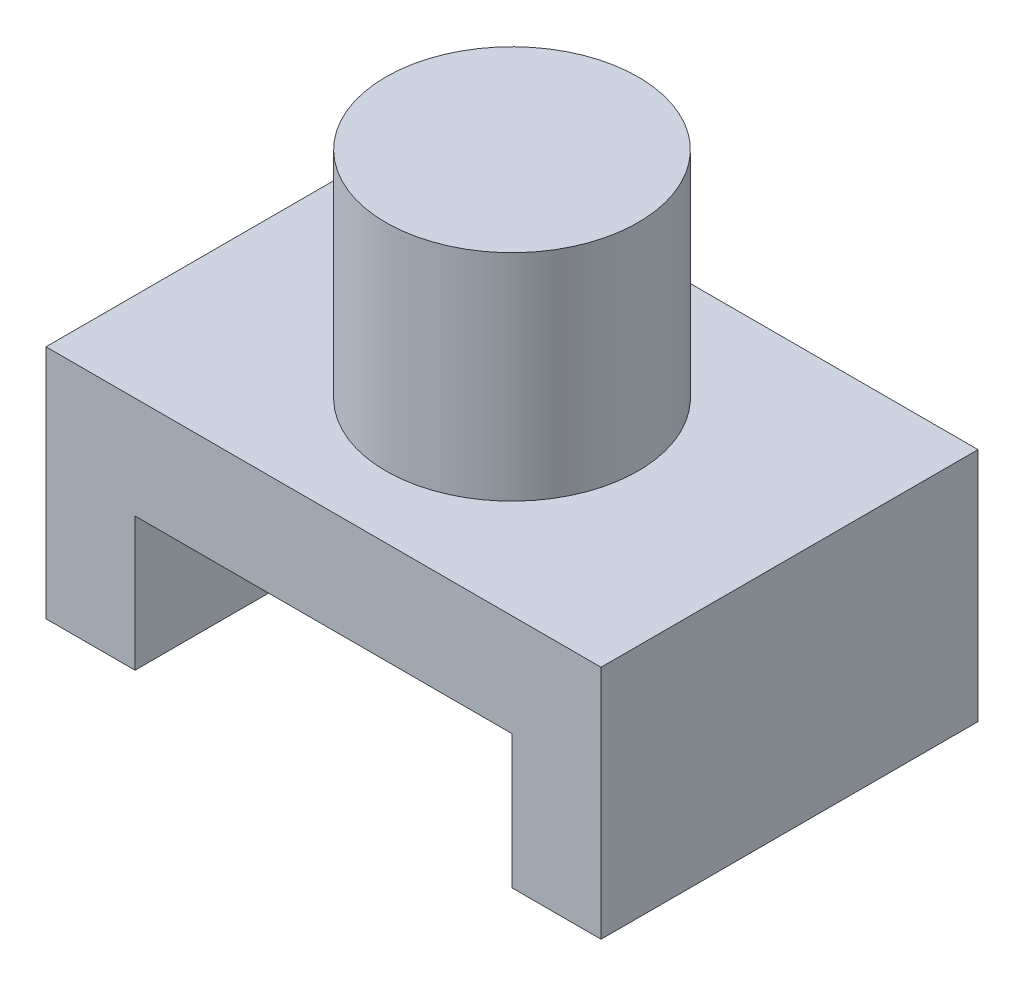
from build123d import *

# Parameters (mm, degrees)
BOSS_EXTRUDE1_DEPTH = 25.4
SKETCH2_R           = 8.5
BOSS_EXTRUDE2_DEPTH = 14.5


with BuildPart() as part:
    # Sketch1 → Boss-Extrude1 (new body)
    with BuildSketch(Plane.XY):
        Polygon((-10.189534884, 0), (-10.189534884, 9), (15.210465116, 9), (15.210465116, 0), (21.210465116, 0), (21.210465116, 15.875), (-16.189534884, 15.875), (-16.189534884, 0), align=None)
    extrude(amount=BOSS_EXTRUDE1_DEPTH)

    # Sketch2 → Boss-Extrude2 (add)
    with BuildSketch(Plane(origin=(0, 15.875, 0), x_dir=(1, 0, 0), z_dir=(0, 1, 0))):
        with Locations((2.510465116, -12.7)):
            Circle(SKETCH2_R)
    extrude(amount=BOSS_EXTRUDE2_DEPTH)


solid = part.part
